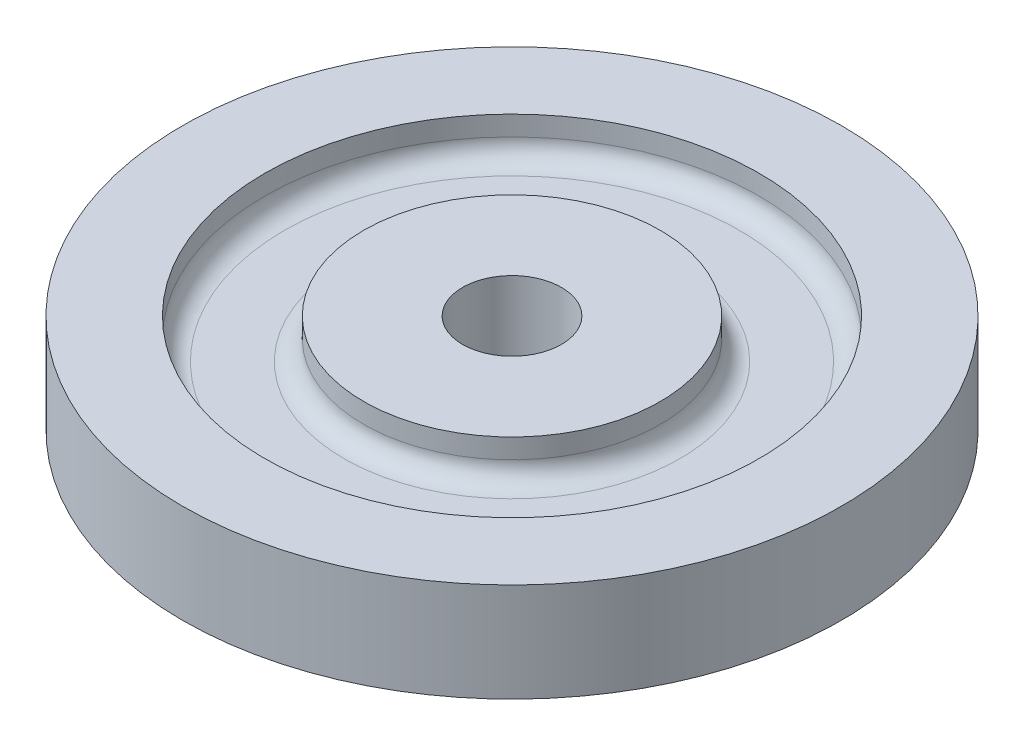
from build123d import *

# Parameters (mm, degrees)
SKETCH1_R           = 42.3291
SKETCH1_R_2         = 6.35
BOSS_EXTRUDE1_DEPTH = 12.7


with BuildPart() as part:
    # Sketch1 → Boss-Extrude1 (new body)
    with BuildSketch(Plane(origin=(0, 0, 0), x_dir=(1, 0, 0), z_dir=(0, 1, 0))):
        Circle(SKETCH1_R)
        Circle(SKETCH1_R_2, mode=Mode.SUBTRACT)
    extrude(amount=BOSS_EXTRUDE1_DEPTH)

    # Cut-Sweep5: sweep along a path in Sketch3
    with BuildLine(Plane(origin=(0, 12.7, 0), x_dir=(1, 0, 0), z_dir=(0, 1, 0))) as cut_sweep5_path:
        CenterArc((0, 0), 25.4, 0, 360)
    # Sketch4 → Cut-Sweep5 (sweep, cut)
    with BuildSketch(Plane.XY):
        with BuildLine():
            Line((-31.75, 12.7), (-19.05, 12.7))
            Line((-19.05, 12.7), (-19.05, 10.16))
            ThreePointArc((-19.05, 10.16), (-19.793948776, 8.363948776), (-21.59, 7.62))
            Line((-21.59, 7.62), (-29.21, 7.62))
            ThreePointArc((-29.21, 7.62), (-31.006051224, 8.363948776), (-31.75, 10.16))
            Line((-31.75, 10.16), (-31.75, 12.7))
        make_face()
    sweep(path=cut_sweep5_path.line, mode=Mode.SUBTRACT)


solid = part.part
